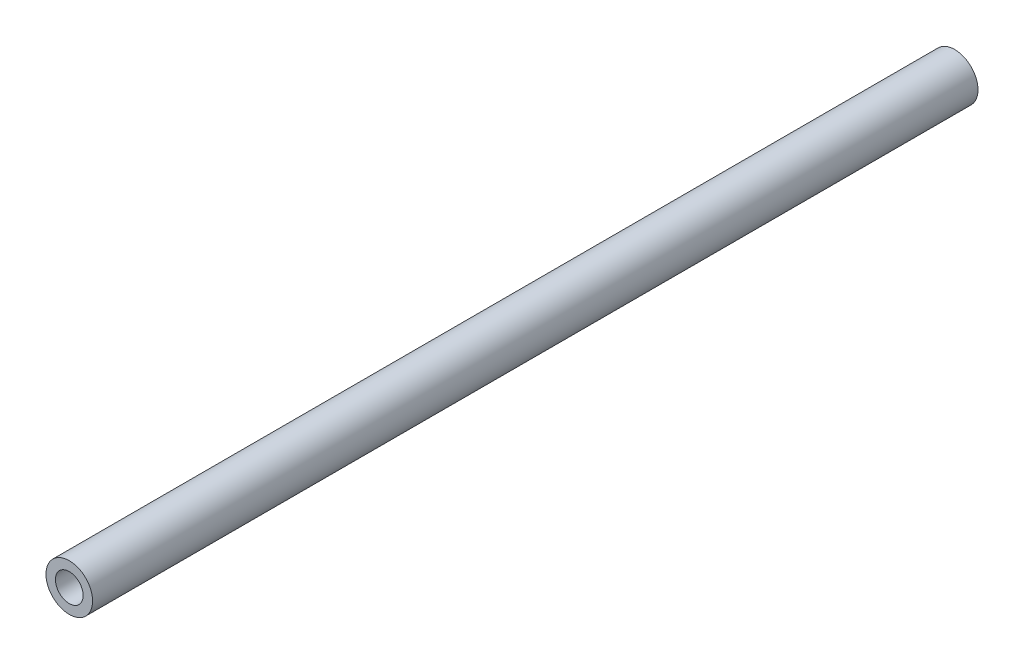
from build123d import *

# Parameters (mm, degrees)
SKETCH1_R           = 7.9
SKETCH1_R_2         = 4.7
BOSS_EXTRUDE1_DEPTH = 300


with BuildPart() as part:
    # Sketch1 → Boss-Extrude1 (new body)
    with BuildSketch(Plane.XY):
        Circle(SKETCH1_R)
        Circle(SKETCH1_R_2, mode=Mode.SUBTRACT)
    extrude(amount=BOSS_EXTRUDE1_DEPTH)


solid = part.part
